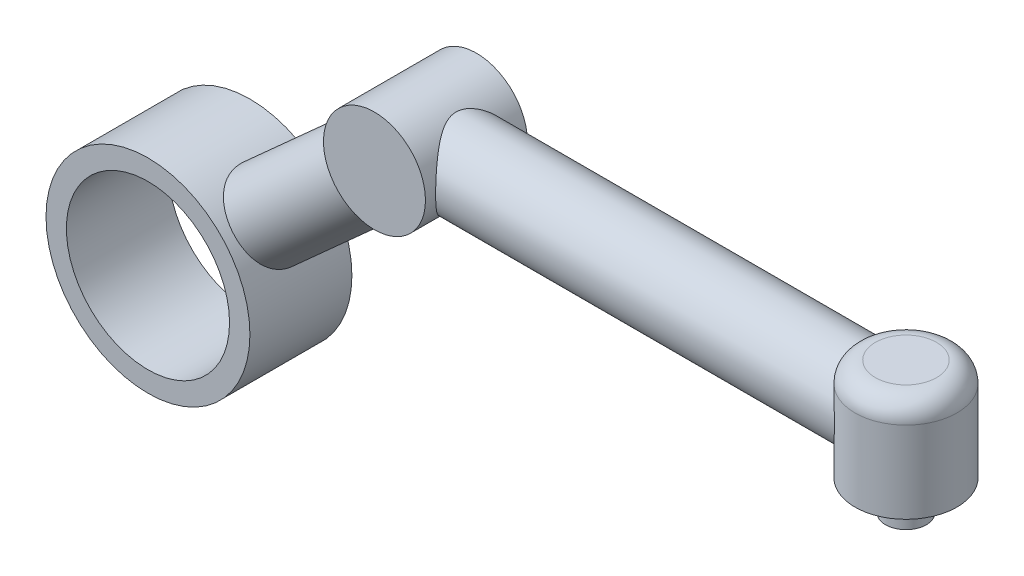
from build123d import *

# Parameters (mm, degrees)
CUT_SWEEP1_PROFILE_R  = 20
SKETCH27_R            = 25
BOSS_EXTRUDE1_DEPTH   = 25
SKETCH27_R_2          = 50
SKETCH27_R_3          = 40
BOSS_EXTRUDE1_2_DEPTH = 25
SWEEP1_PROFILE_R      = 20
CUT_SWEEP2_PROFILE_R  = 15
BOSS_EXTRUDE2_REACH   = 410.831
SKETCH53_R            = 20
SKETCH53_R_2          = 15
BOSS_EXTRUDE3_REACH   = 444.518
SKETCH54_R            = 20
SKETCH54_R_2          = 15
SWEEP2_PROFILE_R      = 20
CUT_SWEEP3_PROFILE_R  = 15
BOSS_EXTRUDE4_REACH   = 575.503
SKETCH84_R            = 20
SKETCH84_R_2          = 15
BOSS_EXTRUDE5_REACH   = 567.775
SKETCH85_R            = 20
SKETCH85_R_2          = 15
SKETCH86_R            = 10
BOSS_EXTRUDE6_DEPTH   = 15


with BuildPart() as part:
    # Sketch3 → Revolve2 (revolve)
    with BuildSketch(Plane.XY):
        with BuildLine():
            Line((438.222956152, -195), (413.222956152, -195))
            Line((413.222956152, -195), (413.222956152, -155))
            ThreePointArc((413.222956152, -155), (416.15188834, -147.928932188), (423.222956152, -145))
            Line((423.222956152, -145), (438.222956152, -145))
            Line((438.222956152, -145), (438.222956152, -195))
        make_face()
    revolve(axis=Axis((438.222956152, -195, 0), (0, 1, 0)))

    # Cut-Sweep1: sweep along a path in Sketch4
    with BuildLine(Plane.XY) as cut_sweep1_path:
        Line((438.222956152, -170), (397.159535172, -170))
    # Cut-Sweep1 profile (on start of the path) → Cut-Sweep1 (sweep, cut)
    with BuildSketch(Plane(origin=(438.222956152, -170, 0), x_dir=(0, 0, -1), z_dir=(-1, 0, 0))):
        Circle(CUT_SWEEP1_PROFILE_R)
    sweep(path=cut_sweep1_path.line, mode=Mode.SUBTRACT)

    # Sketch54 → Boss-Extrude3 (add, up to next)
    with BuildSketch(Plane(origin=(346.162835293, 0, 0), x_dir=(0, 0, -1), z_dir=(1, 0, 0)), mode=Mode.PRIVATE) as boss_extrude3_sk1:
        with Locations((0, -170)):
            Circle(SKETCH54_R)
        with Locations((0, -170)):
            Circle(SKETCH54_R_2, mode=Mode.SUBTRACT)
    boss_extrude3_tool1 = extrude(boss_extrude3_sk1.sketch, amount=BOSS_EXTRUDE3_REACH, mode=Mode.PRIVATE) - part.part


with BuildPart() as body_2:
    # Sketch27 → Boss-Extrude1 (new, symmetric)
    with BuildSketch(Plane.XY):
        with Locations((202.598110741, -170)):
            Circle(SKETCH27_R)
    extrude(amount=BOSS_EXTRUDE1_DEPTH, both=True)

    # Sketch53 → Boss-Extrude2 (add, up to next)
    with BuildSketch(Plane.ZY.offset(-294.751727772), mode=Mode.PRIVATE) as boss_extrude2_sk1:
        with Locations((0, -170)):
            Circle(SKETCH53_R)
        with Locations((0, -170)):
            Circle(SKETCH53_R_2, mode=Mode.SUBTRACT)
    boss_extrude2_tool1 = extrude(boss_extrude2_sk1.sketch, amount=BOSS_EXTRUDE2_REACH, mode=Mode.PRIVATE) - body_2.part


with BuildPart() as body_3:
    # Sketch27 → Boss-Extrude1 2 (new, symmetric)
    with BuildSketch(Plane.XY):
        with Locations((91.536859258, -270)):
            Circle(SKETCH27_R_2)
        with Locations((91.536859258, -270)):
            Circle(SKETCH27_R_3, mode=Mode.SUBTRACT)
    extrude(amount=BOSS_EXTRUDE1_2_DEPTH, both=True)

    # Sketch84 → Boss-Extrude4 (add, up to next)
    with BuildSketch(Plane(origin=(-28.177296889, -25.370952076, 0), x_dir=(0, 0, 1), z_dir=(-0.7431448254773914, -0.6691306063588615, 0)), mode=Mode.PRIVATE) as boss_extrude4_sk1:
        with Locations((0, -261.899217018)):
            Circle(SKETCH84_R)
        with Locations((0, -261.899217018)):
            Circle(SKETCH84_R_2, mode=Mode.SUBTRACT)
    boss_extrude4_tool1 = extrude(boss_extrude4_sk1.sketch, amount=BOSS_EXTRUDE4_REACH, mode=Mode.PRIVATE) - body_3.part


with BuildPart() as body_4:
    # Sweep1: sweep along a path in Sketch28
    with BuildLine(Plane.XY) as sweep1_path:
        Line((294.751727772, -170), (346.162835293, -170))
    # Sweep1 profile (on start of the path) → Sweep1 (sweep)
    with BuildSketch(Plane(origin=(294.751727772, -170, 0), x_dir=(0, 0, 1), z_dir=(1, 0, 0))):
        Circle(SWEEP1_PROFILE_R)
    sweep(path=sweep1_path.line)

    # Cut-Sweep2: sweep along a path in Sketch28_2
    with BuildLine(Plane.XY) as cut_sweep2_path:
        Line((294.751727772, -170), (346.162835293, -170))
    # Cut-Sweep2 profile (on start of the path) → Cut-Sweep2 (sweep, cut)
    with BuildSketch(Plane(origin=(294.751727772, -170, 0), x_dir=(0, 0, 1), z_dir=(1, 0, 0))):
        Circle(CUT_SWEEP2_PROFILE_R)
    sweep(path=cut_sweep2_path.line, mode=Mode.SUBTRACT)


with BuildPart() as body_2_1:
    add(body_2.part)

    add(body_4.part)  # Boss-Extrude2 merges body 4
    add(boss_extrude2_tool1.solids().sort_by_distance((294.751728, -170, -19.434315))[0])


with BuildPart() as part_1:
    add(part.part)

    add(body_2_1.part)  # Boss-Extrude3 merges body 2
    add(boss_extrude3_tool1.solids().sort_by_distance((346.162835, -170, 19.434315))[0])

    # Sketch85 → Boss-Extrude5 (add, up to next)
    with BuildSketch(Plane(origin=(-6.895250114, -6.208511089, 0), x_dir=(0, 0, -1), z_dir=(0.7431448254773914, 0.6691306063588615, 0)), mode=Mode.PRIVATE) as boss_extrude5_sk1:
        with Locations((0, -261.899217018)):
            Circle(SKETCH85_R)
        with Locations((0, -261.899217018)):
            Circle(SKETCH85_R_2, mode=Mode.SUBTRACT)
    boss_extrude5_tool1 = extrude(boss_extrude5_sk1.sketch, amount=BOSS_EXTRUDE5_REACH, mode=Mode.PRIVATE) - part_1.part


with BuildPart() as body_3_2:
    # Sweep2: sweep along a path in Sketch55
    with BuildLine(Plane.XY) as sweep2_path:
        Line((147.067485, -220), (168.349531775, -200.837559013))
    # Sweep2 profile (on start of the path) → Sweep2 (sweep)
    with BuildSketch(Plane(origin=(147.067485, -220, 0), x_dir=(-0.6691306063588623, 0.7431448254773906, 0), z_dir=(0.7431448254773906, 0.6691306063588623, 0))):
        Circle(SWEEP2_PROFILE_R)
    sweep(path=sweep2_path.line)

    # Cut-Sweep3: sweep along a path in Sketch55_2
    with BuildLine(Plane.XY) as cut_sweep3_path:
        Line((147.067485, -220), (168.349531775, -200.837559013))
    # Cut-Sweep3 profile (on start of the path) → Cut-Sweep3 (sweep, cut)
    with BuildSketch(Plane(origin=(147.067485, -220, 0), x_dir=(-0.6691306063588623, 0.7431448254773906, 0), z_dir=(0.7431448254773906, 0.6691306063588623, 0))):
        Circle(CUT_SWEEP3_PROFILE_R)
    sweep(path=cut_sweep3_path.line, mode=Mode.SUBTRACT)


with BuildPart() as body_3_1:
    add(body_3.part)

    add(body_3_2.part)  # Boss-Extrude4 merges body 3 2
    add(boss_extrude4_tool1.solids().sort_by_distance((147.067485, -220, -19.434315))[0])


with BuildPart() as part_2:
    add(part_1.part)

    add(body_3_1.part)  # Boss-Extrude5 merges body 3
    add(boss_extrude5_tool1.solids().sort_by_distance((168.349532, -200.837559, 19.434315))[0])

    # Sketch86 → Boss-Extrude6 (add)
    with BuildSketch(Plane.XZ.offset(195)):
        with Locations((438.222956152, 0)):
            Circle(SKETCH86_R)
    extrude(amount=BOSS_EXTRUDE6_DEPTH)


solid = part_2.part
